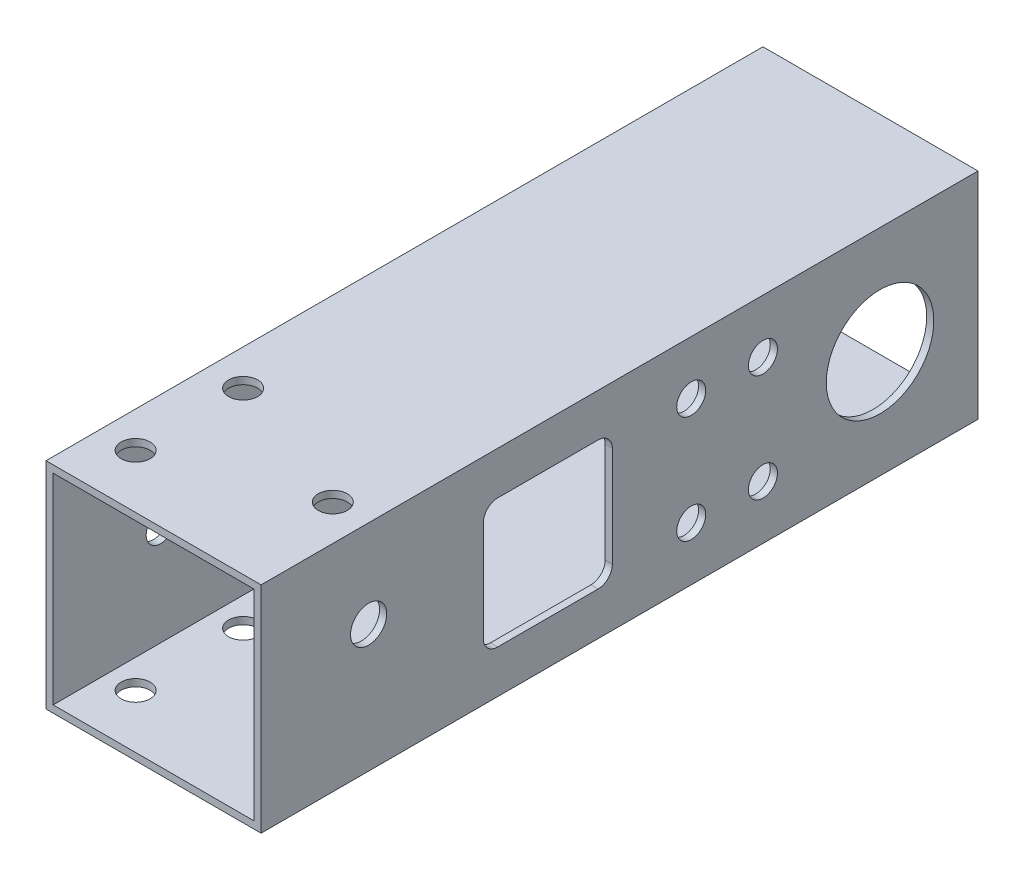
from build123d import *

# Parameters (mm, degrees)
SKETCH_1_W               = 30
SKETCH_1_H               = 30
EXTRUDE_1_DEPTH          = 50
SKETCH_2_W               = 28
SKETCH_2_H               = 28
CUT_EXTRUDE_1_DEPTH      = 1
CUT_EXTRUDE_1_DEPTH_BACK = 101
SKETCH_3_R               = 2.025
CUT_EXTRUDE_2_DEPTH      = 1
SKETCH_4_W               = 18
SKETCH_4_H               = 18
CUT_EXTRUDE_3_DEPTH      = 1
FILLET_1_R               = 2
CUT_EXTRUDE_START        = -2
SKETCH_5_R               = 2.025
CUT_EXTRUDE_5_DEPTH      = 32
SKETCH_6_R               = 2.025
CUT_EXTRUDE_6_DEPTH      = 1
CUT_EXTRUDE_6_DEPTH_BACK = 31
SKETCH_7_R               = 7.5
CUT_EXTRUDE_7_DEPTH      = 1
CUT_EXTRUDE_7_DEPTH_BACK = 31
SKETCH_8_R               = 2.025
CUT_EXTRUDE_8_DEPTH      = 1
CUT_EXTRUDE_8_DEPTH_BACK = 31
SKETCH_9_R               = 2.25
EXTRUDE_2_DEPTH          = 1
SKETCH_10_R              = 2.5
EXTRUDE_3_DEPTH          = 1
SKETCH_11_R              = 2.025
CUT_EXTRUDE_9_DEPTH      = 1
CUT_EXTRUDE_9_DEPTH_BACK = 31
SKETCH_12_R              = 2.5
EXTRUDE_4_DEPTH          = 1
CUT_EXTRUDE_10_REACH     = 32
SKETCH_13_R              = 2.525


with BuildPart() as part:
    # 草图1 → 凸台-拉伸1 (new body, symmetric)
    with BuildSketch(Plane.XY):
        Rectangle(SKETCH_1_W, SKETCH_1_H)
    extrude(amount=EXTRUDE_1_DEPTH, both=True)

    # 草图2 → 切除-拉伸1 (cut, two sides)
    with BuildSketch(Plane.XY.offset(50)) as cut_extrude_1_sk:
        Rectangle(SKETCH_2_W, SKETCH_2_H)
    extrude(amount=CUT_EXTRUDE_1_DEPTH, mode=Mode.SUBTRACT)
    extrude(cut_extrude_1_sk.sketch, amount=-CUT_EXTRUDE_1_DEPTH_BACK, mode=Mode.SUBTRACT)

    # 草图3 → 切除-拉伸2 (cut)
    with BuildSketch(Plane.ZY.offset(15)):
        with Locations((10, 0)):
            Circle(SKETCH_3_R)
        with Locations((35, 0)):
            Circle(SKETCH_3_R)
    extrude(amount=-CUT_EXTRUDE_2_DEPTH, mode=Mode.SUBTRACT)

    # 草图4 → 切除-拉伸3 (cut)
    with BuildSketch(Plane.ZY.offset(-14)):
        with Locations((10, 0)):
            Rectangle(SKETCH_4_W, SKETCH_4_H)
    extrude(amount=-CUT_EXTRUDE_3_DEPTH, mode=Mode.SUBTRACT)

    # 圆角1
    fillet_1_edges = [part.edges().sort_by_distance(p)[0] for p in [
        (14.5, 9, 19),
        (14.5, -9, 19),
        (14.5, -9, 1),
        (14.5, 9, 1),
    ]]
    fillet(fillet_1_edges, radius=FILLET_1_R)

    # 草图5 → 切除-拉伸5 (cut)
    with BuildSketch(Plane(origin=(0, -14, 0), x_dir=(1, 0, 0), z_dir=(0, 1, 0)).offset(CUT_EXTRUDE_START)):
        with Locations((-10, -27.5)):
            Circle(SKETCH_5_R)
        with Locations((-10, -42.5)):
            Circle(SKETCH_5_R)
    cut_extrude_5 = extrude(amount=CUT_EXTRUDE_5_DEPTH, mode=Mode.SUBTRACT)

    # 镜向1: 切除-拉伸5 across plane
    add(cut_extrude_5.mirror(Plane(origin=(0, 0, 0), x_dir=(0, 0, 1), z_dir=(1, 0, 0))), mode=Mode.SUBTRACT)

    # 草图6 → 切除-拉伸6 (cut, two sides)
    with BuildSketch(Plane.ZY.offset(15)) as cut_extrude_6_sk:
        with Locations((35, 0)):
            Circle(SKETCH_6_R)
        with Locations((-20, -7.5)):
            Circle(SKETCH_6_R)
        with Locations((-20, 7.5)):
            Circle(SKETCH_6_R)
    extrude(amount=CUT_EXTRUDE_6_DEPTH, mode=Mode.SUBTRACT)
    extrude(cut_extrude_6_sk.sketch, amount=-CUT_EXTRUDE_6_DEPTH_BACK, mode=Mode.SUBTRACT)

    # 草图7 → 切除-拉伸7 (cut, two sides)
    with BuildSketch(Plane.ZY.offset(15)) as cut_extrude_7_sk:
        with Locations((-36.341476857, 0)):
            Circle(SKETCH_7_R)
    extrude(amount=CUT_EXTRUDE_7_DEPTH, mode=Mode.SUBTRACT)
    extrude(cut_extrude_7_sk.sketch, amount=-CUT_EXTRUDE_7_DEPTH_BACK, mode=Mode.SUBTRACT)

    # 草图8 → 切除-拉伸8 (cut, two sides)
    with BuildSketch(Plane.ZY.offset(15)) as cut_extrude_8_sk:
        with Locations((-10, 7.5)):
            Circle(SKETCH_8_R)
        with Locations((-10, -7.5)):
            Circle(SKETCH_8_R)
    extrude(amount=CUT_EXTRUDE_8_DEPTH, mode=Mode.SUBTRACT)
    extrude(cut_extrude_8_sk.sketch, amount=-CUT_EXTRUDE_8_DEPTH_BACK, mode=Mode.SUBTRACT)

    # 草图9 → 凸台-拉伸2 (add)
    with BuildSketch(Plane(origin=(0, 15, 0), x_dir=(1, 0, 0), z_dir=(0, 1, 0))):
        with Locations((10, -27.5)):
            Circle(SKETCH_9_R)
        with Locations((10, -42.5)):
            Circle(SKETCH_9_R)
    extrude(amount=-EXTRUDE_2_DEPTH)

    # 草图10 → 凸台-拉伸3 (add)
    with BuildSketch(Plane.XZ.offset(15)):
        with Locations((10, 42.5)):
            Circle(SKETCH_10_R)
        with Locations((10, 27.5)):
            Circle(SKETCH_10_R)
    extrude(amount=-EXTRUDE_3_DEPTH)

    # 草图11 → 切除-拉伸9 (cut, two sides)
    with BuildSketch(Plane(origin=(0, 15, 0), x_dir=(1, 0, 0), z_dir=(0, 1, 0))) as cut_extrude_9_sk:
        with Locations((10, -35)):
            Circle(SKETCH_11_R)
    extrude(amount=CUT_EXTRUDE_9_DEPTH, mode=Mode.SUBTRACT)
    extrude(cut_extrude_9_sk.sketch, amount=-CUT_EXTRUDE_9_DEPTH_BACK, mode=Mode.SUBTRACT)

    # 草图12 → 凸台-拉伸4 (add)
    with BuildSketch(Plane(origin=(15, 0, 0), x_dir=(0, 0, -1), z_dir=(1, 0, 0))):
        with Locations((-35, 0)):
            Circle(SKETCH_12_R)
    extrude(amount=-EXTRUDE_4_DEPTH)

    # 草图13 → 切除-拉伸10 (cut, up to next)
    with BuildSketch(Plane(origin=(15, 0, 0), x_dir=(0, 0, -1), z_dir=(1, 0, 0)), mode=Mode.PRIVATE) as cut_extrude_10_sk1:
        with Locations((-35, 2.75)):
            Circle(SKETCH_13_R)
    cut_extrude_10_tool1 = extrude(cut_extrude_10_sk1.sketch, amount=-CUT_EXTRUDE_10_REACH, mode=Mode.PRIVATE) & part.part
    add(cut_extrude_10_tool1.solids().sort_by_distance((15, 2.75, 35))[0], mode=Mode.SUBTRACT)


solid = part.part
